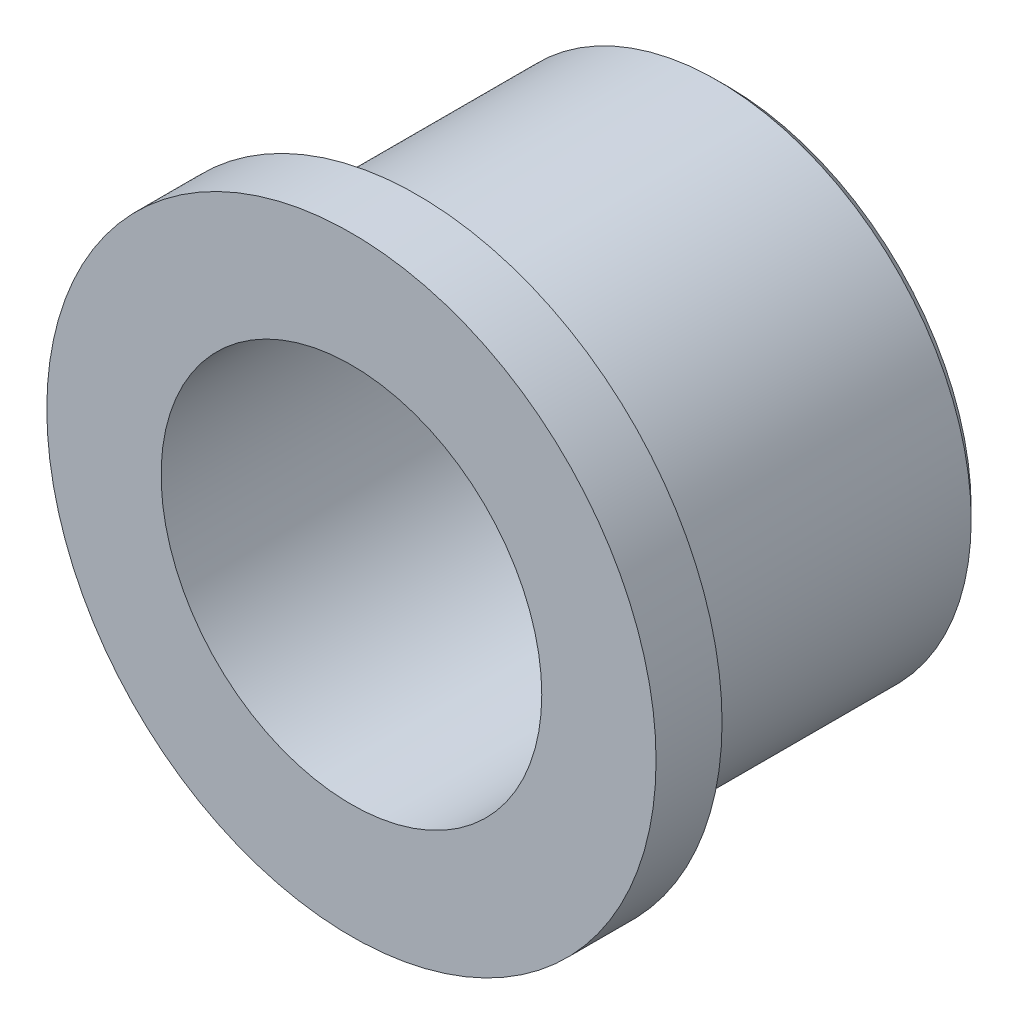
from build123d import *

# Parameters (mm, degrees)
F_1_4_0_75_DIAMETER_HOLE1_D = 19.05
CHAMFER2_SIZE               = 0.508


with BuildPart() as part:
    # Sketch2 → Revolve2 (revolve)
    with BuildSketch(Plane(origin=(0, 0, 0), x_dir=(0, 0, -1), z_dir=(1, 0, 0))):
        Polygon((0, 0), (-18.8214, 0), (-18.8214, 15.244233333), (-15.5194, 15.244233333), (-15.5194, 12.7), (0, 12.7), align=None)
    revolve(axis=Axis((0, 0, 0), (0, 0, -1)))

    # 1_4 _0.75_ Diameter Hole1 (through all)
    with Locations(Plane.XY.offset(18.8214)):
        with Locations((0, 0)):
            Hole(F_1_4_0_75_DIAMETER_HOLE1_D / 2)

    # Chamfer2
    chamfer2_edges = [part.edges().sort_by_distance(p)[0] for p in [
        (0, -12.7, 0),
    ]]
    chamfer(chamfer2_edges, length=CHAMFER2_SIZE)


solid = part.part
